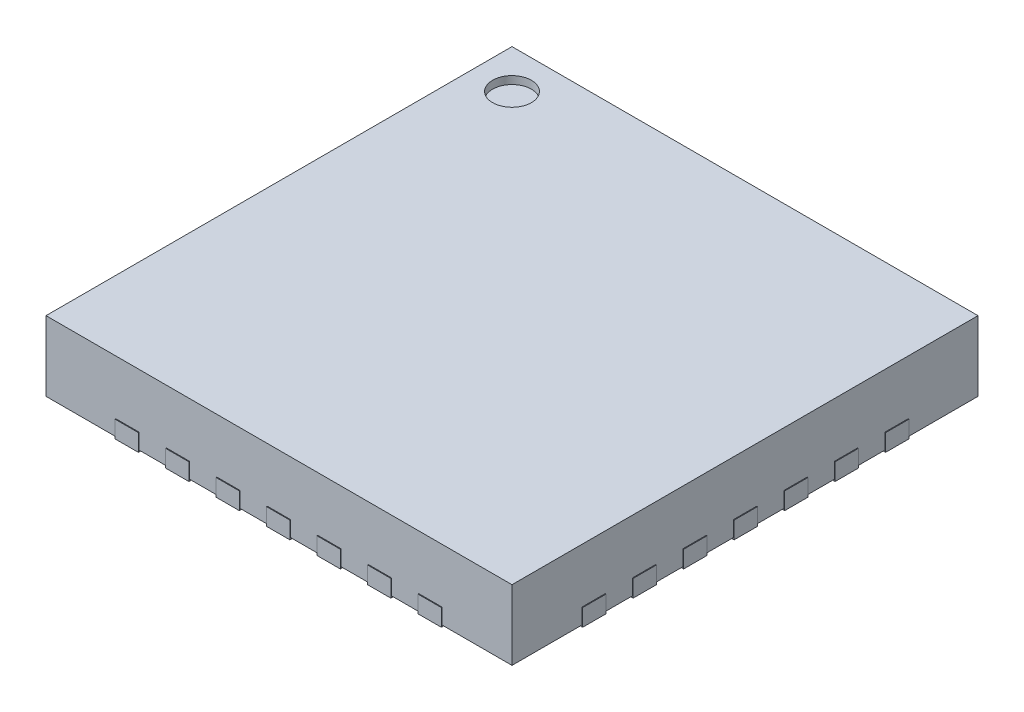
from build123d import *

# Parameters (mm, degrees)
SKETCH2_W                   = 6
SKETCH2_H                   = 6
BOSS_EXTRUDE1_DEPTH         = 0.9
SKETCH3_W                   = 0.4
SKETCH3_H                   = 0.3
BOSS_EXTRUDE2_DEPTH         = 0.02
BOSS_EXTRUDE2_DEPTH_BACK    = 0.2
SKETCH3_W_2                 = 4.8
SKETCH3_H_2                 = 4.8
BOSS_EXTRUDE2_2_DEPTH       = 0.02
BOSS_EXTRUDE2_2_DEPTH_BACK  = 0.2
BOSS_EXTRUDE2_3_DEPTH       = 0.02
BOSS_EXTRUDE2_3_DEPTH_BACK  = 0.2
BOSS_EXTRUDE2_4_DEPTH       = 0.02
BOSS_EXTRUDE2_4_DEPTH_BACK  = 0.2
BOSS_EXTRUDE2_5_DEPTH       = 0.02
BOSS_EXTRUDE2_5_DEPTH_BACK  = 0.2
BOSS_EXTRUDE2_6_DEPTH       = 0.02
BOSS_EXTRUDE2_6_DEPTH_BACK  = 0.2
BOSS_EXTRUDE2_7_DEPTH       = 0.02
BOSS_EXTRUDE2_7_DEPTH_BACK  = 0.2
BOSS_EXTRUDE2_8_DEPTH       = 0.02
BOSS_EXTRUDE2_8_DEPTH_BACK  = 0.2
SKETCH3_W_3                 = 0.3
SKETCH3_H_3                 = 0.4
BOSS_EXTRUDE2_9_DEPTH       = 0.02
BOSS_EXTRUDE2_9_DEPTH_BACK  = 0.2
BOSS_EXTRUDE2_10_DEPTH      = 0.02
BOSS_EXTRUDE2_10_DEPTH_BACK = 0.2
BOSS_EXTRUDE2_11_DEPTH      = 0.02
BOSS_EXTRUDE2_11_DEPTH_BACK = 0.2
BOSS_EXTRUDE2_12_DEPTH      = 0.02
BOSS_EXTRUDE2_12_DEPTH_BACK = 0.2
BOSS_EXTRUDE2_13_DEPTH      = 0.02
BOSS_EXTRUDE2_13_DEPTH_BACK = 0.2
BOSS_EXTRUDE2_14_DEPTH      = 0.02
BOSS_EXTRUDE2_14_DEPTH_BACK = 0.2
BOSS_EXTRUDE2_15_DEPTH      = 0.02
BOSS_EXTRUDE2_15_DEPTH_BACK = 0.2
BOSS_EXTRUDE2_16_DEPTH      = 0.02
BOSS_EXTRUDE2_16_DEPTH_BACK = 0.2
BOSS_EXTRUDE2_17_DEPTH      = 0.02
BOSS_EXTRUDE2_17_DEPTH_BACK = 0.2
BOSS_EXTRUDE2_18_DEPTH      = 0.02
BOSS_EXTRUDE2_18_DEPTH_BACK = 0.2
BOSS_EXTRUDE2_19_DEPTH      = 0.02
BOSS_EXTRUDE2_19_DEPTH_BACK = 0.2
BOSS_EXTRUDE2_20_DEPTH      = 0.02
BOSS_EXTRUDE2_20_DEPTH_BACK = 0.2
BOSS_EXTRUDE2_21_DEPTH      = 0.02
BOSS_EXTRUDE2_21_DEPTH_BACK = 0.2
BOSS_EXTRUDE2_22_DEPTH      = 0.02
BOSS_EXTRUDE2_22_DEPTH_BACK = 0.2
BOSS_EXTRUDE2_23_DEPTH      = 0.02
BOSS_EXTRUDE2_23_DEPTH_BACK = 0.2
BOSS_EXTRUDE2_24_DEPTH      = 0.02
BOSS_EXTRUDE2_24_DEPTH_BACK = 0.2
BOSS_EXTRUDE2_25_DEPTH      = 0.02
BOSS_EXTRUDE2_25_DEPTH_BACK = 0.2
BOSS_EXTRUDE2_26_DEPTH      = 0.02
BOSS_EXTRUDE2_26_DEPTH_BACK = 0.2
BOSS_EXTRUDE2_27_DEPTH      = 0.02
BOSS_EXTRUDE2_27_DEPTH_BACK = 0.2
BOSS_EXTRUDE2_28_DEPTH      = 0.02
BOSS_EXTRUDE2_28_DEPTH_BACK = 0.2
BOSS_EXTRUDE2_29_DEPTH      = 0.02
BOSS_EXTRUDE2_29_DEPTH_BACK = 0.2
SKETCH4_R                   = 0.25
CUT_EXTRUDE1_DEPTH          = 0.1


with BuildPart() as part:
    # Sketch2 → Boss-Extrude1 (new body)
    with BuildSketch(Plane(origin=(0, 0, 0), x_dir=(1, 0, 0), z_dir=(0, 1, 0))):
        Rectangle(SKETCH2_W, SKETCH2_H)
    extrude(amount=BOSS_EXTRUDE1_DEPTH)

    # Sketch4 → Cut-Extrude1 (cut)
    with BuildSketch(Plane(origin=(0, 0.9, 0), x_dir=(1, 0, 0), z_dir=(0, 1, 0))):
        with Locations((-2.5, 2.5)):
            Circle(SKETCH4_R)
    extrude(amount=-CUT_EXTRUDE1_DEPTH, mode=Mode.SUBTRACT)


with BuildPart() as body_2:
    # Sketch3 → Boss-Extrude2 (new body, two sides)
    with BuildSketch(Plane.XZ) as boss_extrude2_sk:
        with Locations((-2.81, 0.65)):
            Rectangle(SKETCH3_W, SKETCH3_H)
    extrude(amount=BOSS_EXTRUDE2_DEPTH)
    extrude(boss_extrude2_sk.sketch, amount=-BOSS_EXTRUDE2_DEPTH_BACK)


with BuildPart() as body_3:
    # Sketch3 → Boss-Extrude2 2 (new body, two sides)
    with BuildSketch(Plane.XZ) as boss_extrude2_2_sk:
        Rectangle(SKETCH3_W_2, SKETCH3_H_2)
    extrude(amount=BOSS_EXTRUDE2_2_DEPTH)
    extrude(boss_extrude2_2_sk.sketch, amount=-BOSS_EXTRUDE2_2_DEPTH_BACK)


with BuildPart() as body_4:
    # Sketch3 → Boss-Extrude2 3 (new body, two sides)
    with BuildSketch(Plane.XZ) as boss_extrude2_3_sk:
        with Locations((-2.81, 0)):
            Rectangle(SKETCH3_W, SKETCH3_H)
    extrude(amount=BOSS_EXTRUDE2_3_DEPTH)
    extrude(boss_extrude2_3_sk.sketch, amount=-BOSS_EXTRUDE2_3_DEPTH_BACK)


with BuildPart() as body_5:
    # Sketch3 → Boss-Extrude2 4 (new body, two sides)
    with BuildSketch(Plane.XZ) as boss_extrude2_4_sk:
        with Locations((-2.81, 1.3)):
            Rectangle(SKETCH3_W, SKETCH3_H)
    extrude(amount=BOSS_EXTRUDE2_4_DEPTH)
    extrude(boss_extrude2_4_sk.sketch, amount=-BOSS_EXTRUDE2_4_DEPTH_BACK)


with BuildPart() as body_6:
    # Sketch3 → Boss-Extrude2 5 (new body, two sides)
    with BuildSketch(Plane.XZ) as boss_extrude2_5_sk:
        with Locations((-2.81, 1.95)):
            Rectangle(SKETCH3_W, SKETCH3_H)
    extrude(amount=BOSS_EXTRUDE2_5_DEPTH)
    extrude(boss_extrude2_5_sk.sketch, amount=-BOSS_EXTRUDE2_5_DEPTH_BACK)


with BuildPart() as body_7:
    # Sketch3 → Boss-Extrude2 6 (new body, two sides)
    with BuildSketch(Plane.XZ) as boss_extrude2_6_sk:
        with Locations((-2.81, -1.95)):
            Rectangle(SKETCH3_W, SKETCH3_H)
    extrude(amount=BOSS_EXTRUDE2_6_DEPTH)
    extrude(boss_extrude2_6_sk.sketch, amount=-BOSS_EXTRUDE2_6_DEPTH_BACK)


with BuildPart() as body_8:
    # Sketch3 → Boss-Extrude2 7 (new body, two sides)
    with BuildSketch(Plane.XZ) as boss_extrude2_7_sk:
        with Locations((-2.81, -1.3)):
            Rectangle(SKETCH3_W, SKETCH3_H)
    extrude(amount=BOSS_EXTRUDE2_7_DEPTH)
    extrude(boss_extrude2_7_sk.sketch, amount=-BOSS_EXTRUDE2_7_DEPTH_BACK)


with BuildPart() as body_9:
    # Sketch3 → Boss-Extrude2 8 (new body, two sides)
    with BuildSketch(Plane.XZ) as boss_extrude2_8_sk:
        with Locations((-2.81, -0.65)):
            Rectangle(SKETCH3_W, SKETCH3_H)
    extrude(amount=BOSS_EXTRUDE2_8_DEPTH)
    extrude(boss_extrude2_8_sk.sketch, amount=-BOSS_EXTRUDE2_8_DEPTH_BACK)


with BuildPart() as body_10:
    # Sketch3 → Boss-Extrude2 9 (new body, two sides)
    with BuildSketch(Plane.XZ) as boss_extrude2_9_sk:
        with Locations((1.95, 2.81)):
            Rectangle(SKETCH3_W_3, SKETCH3_H_3)
    extrude(amount=BOSS_EXTRUDE2_9_DEPTH)
    extrude(boss_extrude2_9_sk.sketch, amount=-BOSS_EXTRUDE2_9_DEPTH_BACK)


with BuildPart() as body_11:
    # Sketch3 → Boss-Extrude2 10 (new body, two sides)
    with BuildSketch(Plane.XZ) as boss_extrude2_10_sk:
        with Locations((1.3, 2.81)):
            Rectangle(SKETCH3_W_3, SKETCH3_H_3)
    extrude(amount=BOSS_EXTRUDE2_10_DEPTH)
    extrude(boss_extrude2_10_sk.sketch, amount=-BOSS_EXTRUDE2_10_DEPTH_BACK)


with BuildPart() as body_12:
    # Sketch3 → Boss-Extrude2 11 (new body, two sides)
    with BuildSketch(Plane.XZ) as boss_extrude2_11_sk:
        with Locations((0.65, 2.81)):
            Rectangle(SKETCH3_W_3, SKETCH3_H_3)
    extrude(amount=BOSS_EXTRUDE2_11_DEPTH)
    extrude(boss_extrude2_11_sk.sketch, amount=-BOSS_EXTRUDE2_11_DEPTH_BACK)


with BuildPart() as body_13:
    # Sketch3 → Boss-Extrude2 12 (new body, two sides)
    with BuildSketch(Plane.XZ) as boss_extrude2_12_sk:
        with Locations((0, 2.81)):
            Rectangle(SKETCH3_W_3, SKETCH3_H_3)
    extrude(amount=BOSS_EXTRUDE2_12_DEPTH)
    extrude(boss_extrude2_12_sk.sketch, amount=-BOSS_EXTRUDE2_12_DEPTH_BACK)


with BuildPart() as body_14:
    # Sketch3 → Boss-Extrude2 13 (new body, two sides)
    with BuildSketch(Plane.XZ) as boss_extrude2_13_sk:
        with Locations((-0.65, 2.81)):
            Rectangle(SKETCH3_W_3, SKETCH3_H_3)
    extrude(amount=BOSS_EXTRUDE2_13_DEPTH)
    extrude(boss_extrude2_13_sk.sketch, amount=-BOSS_EXTRUDE2_13_DEPTH_BACK)


with BuildPart() as body_15:
    # Sketch3 → Boss-Extrude2 14 (new body, two sides)
    with BuildSketch(Plane.XZ) as boss_extrude2_14_sk:
        with Locations((-1.3, 2.81)):
            Rectangle(SKETCH3_W_3, SKETCH3_H_3)
    extrude(amount=BOSS_EXTRUDE2_14_DEPTH)
    extrude(boss_extrude2_14_sk.sketch, amount=-BOSS_EXTRUDE2_14_DEPTH_BACK)


with BuildPart() as body_16:
    # Sketch3 → Boss-Extrude2 15 (new body, two sides)
    with BuildSketch(Plane.XZ) as boss_extrude2_15_sk:
        with Locations((-1.95, 2.81)):
            Rectangle(SKETCH3_W_3, SKETCH3_H_3)
    extrude(amount=BOSS_EXTRUDE2_15_DEPTH)
    extrude(boss_extrude2_15_sk.sketch, amount=-BOSS_EXTRUDE2_15_DEPTH_BACK)


with BuildPart() as body_17:
    # Sketch3 → Boss-Extrude2 16 (new body, two sides)
    with BuildSketch(Plane.XZ) as boss_extrude2_16_sk:
        with Locations((2.81, -1.95)):
            Rectangle(SKETCH3_W, SKETCH3_H)
    extrude(amount=BOSS_EXTRUDE2_16_DEPTH)
    extrude(boss_extrude2_16_sk.sketch, amount=-BOSS_EXTRUDE2_16_DEPTH_BACK)


with BuildPart() as body_18:
    # Sketch3 → Boss-Extrude2 17 (new body, two sides)
    with BuildSketch(Plane.XZ) as boss_extrude2_17_sk:
        with Locations((2.81, -1.3)):
            Rectangle(SKETCH3_W, SKETCH3_H)
    extrude(amount=BOSS_EXTRUDE2_17_DEPTH)
    extrude(boss_extrude2_17_sk.sketch, amount=-BOSS_EXTRUDE2_17_DEPTH_BACK)


with BuildPart() as body_19:
    # Sketch3 → Boss-Extrude2 18 (new body, two sides)
    with BuildSketch(Plane.XZ) as boss_extrude2_18_sk:
        with Locations((2.81, -0.65)):
            Rectangle(SKETCH3_W, SKETCH3_H)
    extrude(amount=BOSS_EXTRUDE2_18_DEPTH)
    extrude(boss_extrude2_18_sk.sketch, amount=-BOSS_EXTRUDE2_18_DEPTH_BACK)


with BuildPart() as body_20:
    # Sketch3 → Boss-Extrude2 19 (new body, two sides)
    with BuildSketch(Plane.XZ) as boss_extrude2_19_sk:
        with Locations((2.81, 0)):
            Rectangle(SKETCH3_W, SKETCH3_H)
    extrude(amount=BOSS_EXTRUDE2_19_DEPTH)
    extrude(boss_extrude2_19_sk.sketch, amount=-BOSS_EXTRUDE2_19_DEPTH_BACK)


with BuildPart() as body_21:
    # Sketch3 → Boss-Extrude2 20 (new body, two sides)
    with BuildSketch(Plane.XZ) as boss_extrude2_20_sk:
        with Locations((2.81, 0.65)):
            Rectangle(SKETCH3_W, SKETCH3_H)
    extrude(amount=BOSS_EXTRUDE2_20_DEPTH)
    extrude(boss_extrude2_20_sk.sketch, amount=-BOSS_EXTRUDE2_20_DEPTH_BACK)


with BuildPart() as body_22:
    # Sketch3 → Boss-Extrude2 21 (new body, two sides)
    with BuildSketch(Plane.XZ) as boss_extrude2_21_sk:
        with Locations((2.81, 1.3)):
            Rectangle(SKETCH3_W, SKETCH3_H)
    extrude(amount=BOSS_EXTRUDE2_21_DEPTH)
    extrude(boss_extrude2_21_sk.sketch, amount=-BOSS_EXTRUDE2_21_DEPTH_BACK)


with BuildPart() as body_23:
    # Sketch3 → Boss-Extrude2 22 (new body, two sides)
    with BuildSketch(Plane.XZ) as boss_extrude2_22_sk:
        with Locations((2.81, 1.95)):
            Rectangle(SKETCH3_W, SKETCH3_H)
    extrude(amount=BOSS_EXTRUDE2_22_DEPTH)
    extrude(boss_extrude2_22_sk.sketch, amount=-BOSS_EXTRUDE2_22_DEPTH_BACK)


with BuildPart() as body_24:
    # Sketch3 → Boss-Extrude2 23 (new body, two sides)
    with BuildSketch(Plane.XZ) as boss_extrude2_23_sk:
        with Locations((-1.95, -2.81)):
            Rectangle(SKETCH3_W_3, SKETCH3_H_3)
    extrude(amount=BOSS_EXTRUDE2_23_DEPTH)
    extrude(boss_extrude2_23_sk.sketch, amount=-BOSS_EXTRUDE2_23_DEPTH_BACK)


with BuildPart() as body_25:
    # Sketch3 → Boss-Extrude2 24 (new body, two sides)
    with BuildSketch(Plane.XZ) as boss_extrude2_24_sk:
        with Locations((-1.3, -2.81)):
            Rectangle(SKETCH3_W_3, SKETCH3_H_3)
    extrude(amount=BOSS_EXTRUDE2_24_DEPTH)
    extrude(boss_extrude2_24_sk.sketch, amount=-BOSS_EXTRUDE2_24_DEPTH_BACK)


with BuildPart() as body_26:
    # Sketch3 → Boss-Extrude2 25 (new body, two sides)
    with BuildSketch(Plane.XZ) as boss_extrude2_25_sk:
        with Locations((-0.65, -2.81)):
            Rectangle(SKETCH3_W_3, SKETCH3_H_3)
    extrude(amount=BOSS_EXTRUDE2_25_DEPTH)
    extrude(boss_extrude2_25_sk.sketch, amount=-BOSS_EXTRUDE2_25_DEPTH_BACK)


with BuildPart() as body_27:
    # Sketch3 → Boss-Extrude2 26 (new body, two sides)
    with BuildSketch(Plane.XZ) as boss_extrude2_26_sk:
        with Locations((0, -2.81)):
            Rectangle(SKETCH3_W_3, SKETCH3_H_3)
    extrude(amount=BOSS_EXTRUDE2_26_DEPTH)
    extrude(boss_extrude2_26_sk.sketch, amount=-BOSS_EXTRUDE2_26_DEPTH_BACK)


with BuildPart() as body_28:
    # Sketch3 → Boss-Extrude2 27 (new body, two sides)
    with BuildSketch(Plane.XZ) as boss_extrude2_27_sk:
        with Locations((0.65, -2.81)):
            Rectangle(SKETCH3_W_3, SKETCH3_H_3)
    extrude(amount=BOSS_EXTRUDE2_27_DEPTH)
    extrude(boss_extrude2_27_sk.sketch, amount=-BOSS_EXTRUDE2_27_DEPTH_BACK)


with BuildPart() as body_29:
    # Sketch3 → Boss-Extrude2 28 (new body, two sides)
    with BuildSketch(Plane.XZ) as boss_extrude2_28_sk:
        with Locations((1.3, -2.81)):
            Rectangle(SKETCH3_W_3, SKETCH3_H_3)
    extrude(amount=BOSS_EXTRUDE2_28_DEPTH)
    extrude(boss_extrude2_28_sk.sketch, amount=-BOSS_EXTRUDE2_28_DEPTH_BACK)


with BuildPart() as body_30:
    # Sketch3 → Boss-Extrude2 29 (new body, two sides)
    with BuildSketch(Plane.XZ) as boss_extrude2_29_sk:
        with Locations((1.95, -2.81)):
            Rectangle(SKETCH3_W_3, SKETCH3_H_3)
    extrude(amount=BOSS_EXTRUDE2_29_DEPTH)
    extrude(boss_extrude2_29_sk.sketch, amount=-BOSS_EXTRUDE2_29_DEPTH_BACK)


solid = Compound([part.part, body_2.part, body_3.part, body_4.part, body_5.part, body_6.part, body_7.part, body_8.part, body_9.part, body_10.part, body_11.part, body_12.part, body_13.part, body_14.part, body_15.part, body_16.part, body_17.part, body_18.part, body_19.part, body_20.part, body_21.part, body_22.part, body_23.part, body_24.part, body_25.part, body_26.part, body_27.part, body_28.part, body_29.part, body_30.part])
